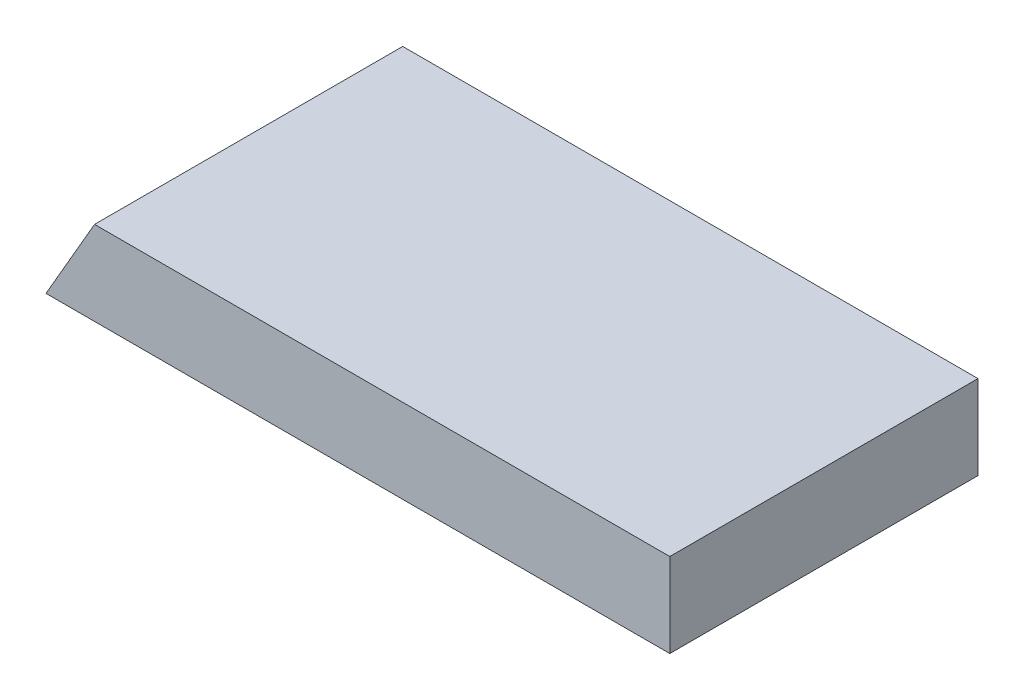
from build123d import *

# Parameters (mm, degrees)
SKETCH1_W           = 381
SKETCH1_H           = 139.7
BOSS_EXTRUDE1_DEPTH = 38.1
CUT_EXTRUDE2_DEPTH  = 140.7


with BuildPart() as part:
    # Sketch1 → Boss-Extrude1 (new body)
    with BuildSketch(Plane(origin=(0, 0, 0), x_dir=(1, 0, 0), z_dir=(0, 1, 0))):
        with Locations((190.5, 69.85)):
            Rectangle(SKETCH1_W, SKETCH1_H)
    extrude(amount=BOSS_EXTRUDE1_DEPTH)

    # Sketch2 → Cut-Extrude2 (cut, through all)
    with BuildSketch(Plane.XY):
        Polygon((98.256184637, 0), (120.253229893, 38.1), (0, 38.1), (0, 0), align=None)
    extrude(amount=-CUT_EXTRUDE2_DEPTH, mode=Mode.SUBTRACT)


solid = part.part
